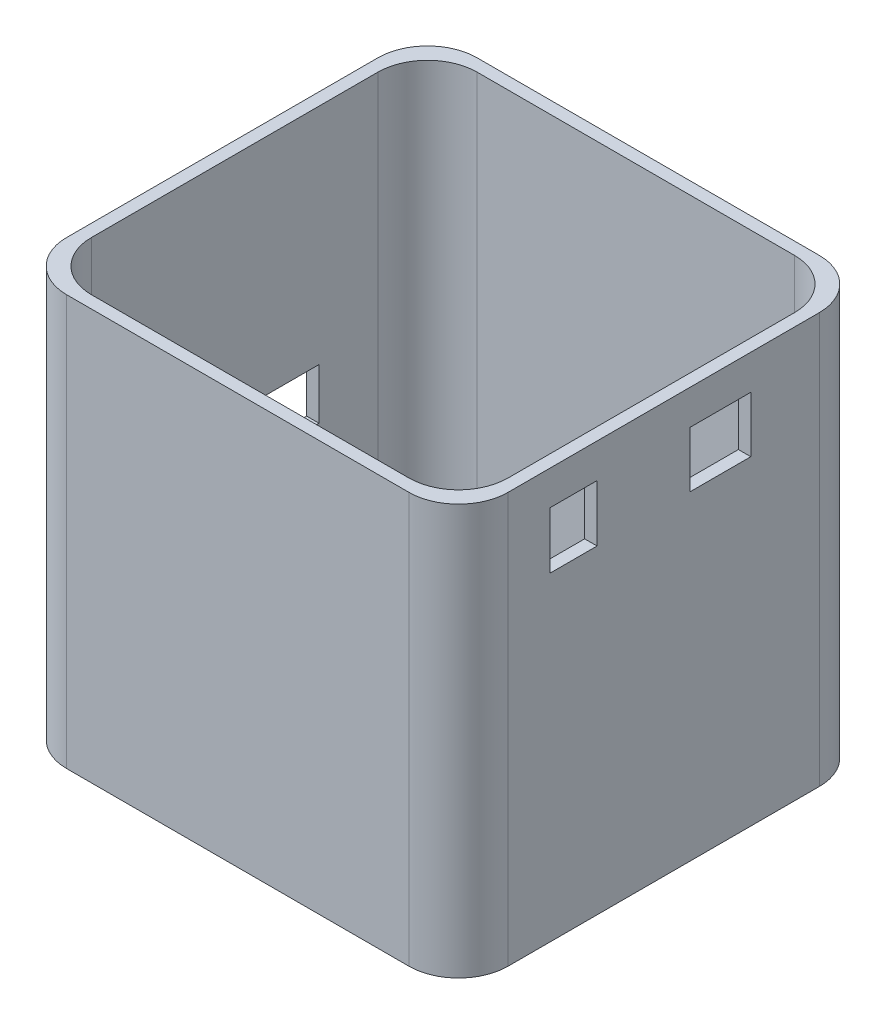
from build123d import *

# Parameters (mm, degrees)
SKETCH1_W           = 90.424
SKETCH1_H           = 84.074
BOSS_EXTRUDE1_DEPTH = 84.074
SKETCH3_W           = 85.344
SKETCH3_H           = 78.994
CUT_EXTRUDE1_DEPTH  = 81.534
SKETCH5_W           = 34.544
SKETCH5_H           = 10.414
CUT_EXTRUDE3_DEPTH  = 7.62
FILLET1_R           = 10.16
SKETCH6_W           = 9.652
SKETCH6_H           = 11.608529125
SKETCH6_W_2         = 12.446
SKETCH6_H_2         = 11.43
CUT_EXTRUDE4_DEPTH  = 5.08


with BuildPart() as part:
    # Sketch1 → Boss-Extrude1 (new body)
    with BuildSketch(Plane(origin=(0, 0, 0), x_dir=(1, 0, 0), z_dir=(0, 1, 0))):
        Rectangle(SKETCH1_W, SKETCH1_H)
    extrude(amount=BOSS_EXTRUDE1_DEPTH)

    # Sketch3 → Cut-Extrude1 (cut)
    with BuildSketch(Plane(origin=(0, 84.074, 0), x_dir=(1, 0, 0), z_dir=(0, 1, 0))):
        Rectangle(SKETCH3_W, SKETCH3_H)
    extrude(amount=-CUT_EXTRUDE1_DEPTH, mode=Mode.SUBTRACT)

    # Sketch5 → Cut-Extrude3 (cut)
    with BuildSketch(Plane.ZY.offset(45.212)):
        with Locations((0, 33.02)):
            Rectangle(SKETCH5_W, SKETCH5_H)
    extrude(amount=-CUT_EXTRUDE3_DEPTH, mode=Mode.SUBTRACT)

    # Fillet1
    fillet1_edges = [part.edges().sort_by_distance(p)[0] for p in [
        (42.672, 43.307, -39.497),
        (42.672, 43.307, 39.497),
        (-42.672, 43.307, 39.497),
        (-42.672, 43.307, -39.497),
        (45.212, 42.037, 42.037),
        (-45.212, 42.037, 42.037),
        (-45.212, 42.037, -42.037),
        (45.212, 42.037, -42.037),
    ]]
    fillet(fillet1_edges, radius=FILLET1_R)

    # Sketch6 → Cut-Extrude4 (cut)
    with BuildSketch(Plane(origin=(45.212, 0, 0), x_dir=(0, 0, -1), z_dir=(1, 0, 0))):
        with Locations((-18.477409208, 71.239969556)):
            Rectangle(SKETCH6_W, SKETCH6_H)
        with Locations((11.621294262, 71.24718083)):
            Rectangle(SKETCH6_W_2, SKETCH6_H_2)
    extrude(amount=-CUT_EXTRUDE4_DEPTH, mode=Mode.SUBTRACT)


solid = part.part
